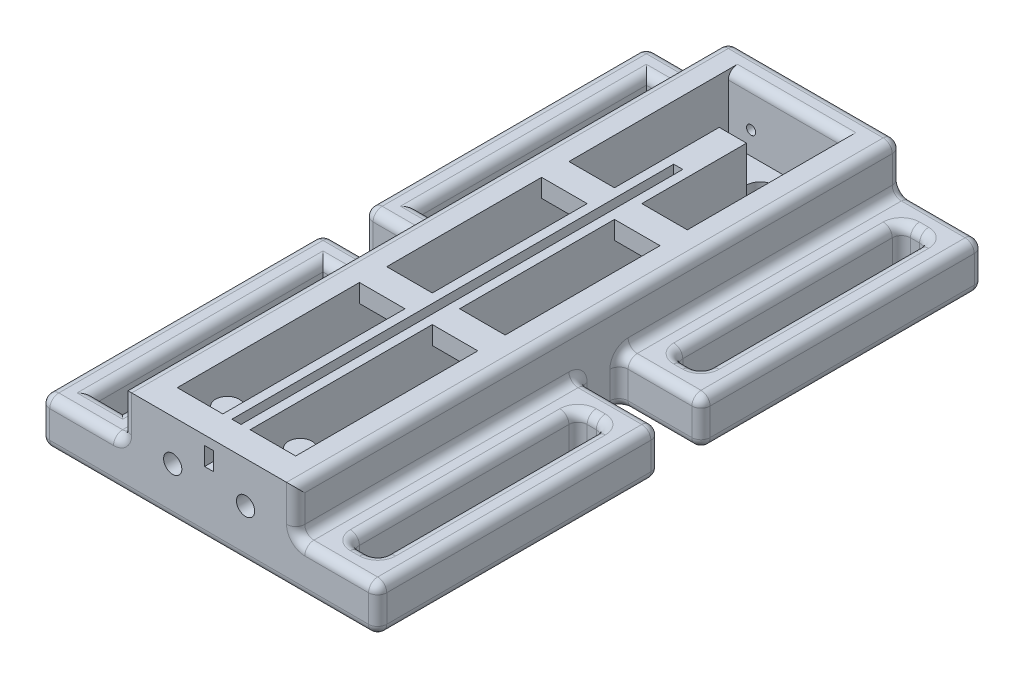
from build123d import *

# Parameters (mm, degrees)
SKETCH1_W           = 19
SKETCH1_H           = 66.5
BOSS_EXTRUDE2_DEPTH = 10
SKETCH2_W           = 5
SKETCH2_H           = 60.5
CUT_EXTRUDE1_DEPTH  = 7
SKETCH3_W           = 9
SKETCH3_H           = 31
SKETCH3_W_2         = 3
SKETCH3_H_2         = 25
BOSS_EXTRUDE3_DEPTH = 5
SKETCH4_R           = 1.3
BOSS_EXTRUDE4_DEPTH = 5
SKETCH5_W           = 13
SKETCH5_H           = 3
BOSS_EXTRUDE5_DEPTH = 2
SKETCH6_R           = 1.51
CUT_EXTRUDE4_DEPTH  = 10
SKETCH7_W           = 3
SKETCH7_H           = 6
CUT_EXTRUDE5_DEPTH  = 7
SKETCH10_R          = 0.5
CUT_EXTRUDE6_DEPTH  = 3
SKETCH11_R          = 1
CUT_EXTRUDE7_DEPTH  = 3
CUT_EXTRUDE8_DEPTH  = 3
SKETCH13_W          = 1
SKETCH13_H          = 2
CUT_EXTRUDE9_DEPTH  = 68
FILLET1_R           = 1


with BuildPart() as part:
    # Sketch1 → Boss-Extrude2 (new body)
    with BuildSketch(Plane(origin=(0, 0, 0), x_dir=(1, 0, 0), z_dir=(0, 1, 0))):
        with Locations((9.5, 33.25)):
            Rectangle(SKETCH1_W, SKETCH1_H)
    extrude(amount=BOSS_EXTRUDE2_DEPTH)

    # Sketch2 → Cut-Extrude1 (cut)
    with BuildSketch(Plane(origin=(0, 10, 0), x_dir=(1, 0, 0), z_dir=(0, 1, 0))):
        with Locations((5.5, 33.25)):
            Rectangle(SKETCH2_W, SKETCH2_H)
        with Locations((13.5, 33.25)):
            Rectangle(SKETCH2_W, SKETCH2_H)
    extrude(amount=-CUT_EXTRUDE1_DEPTH, mode=Mode.SUBTRACT)

    # Sketch3 → Boss-Extrude3 (add)
    with BuildSketch(Plane(origin=(0, 0, 0), x_dir=(1, 0, 0), z_dir=(0, 1, 0))):
        with Locations((-4.5, 15.5)):
            Rectangle(SKETCH3_W, SKETCH3_H)
        with Locations((-4.5, 15.5)):
            Rectangle(SKETCH3_W_2, SKETCH3_H_2, mode=Mode.SUBTRACT)
        with Locations((23.5, 15.5)):
            Rectangle(SKETCH3_W, SKETCH3_H)
        with Locations((23.5, 15.5)):
            Rectangle(SKETCH3_W_2, SKETCH3_H_2, mode=Mode.SUBTRACT)
        with Locations((-4.5, 51)):
            Rectangle(SKETCH3_W, SKETCH3_H)
        with Locations((-4.5, 51)):
            Rectangle(SKETCH3_W_2, SKETCH3_H_2, mode=Mode.SUBTRACT)
        with Locations((23.5, 51)):
            Rectangle(SKETCH3_W, SKETCH3_H)
        with Locations((23.5, 51)):
            Rectangle(SKETCH3_W_2, SKETCH3_H_2, mode=Mode.SUBTRACT)
    extrude(amount=BOSS_EXTRUDE3_DEPTH)

    # Sketch4 → Boss-Extrude4 (add)
    with BuildSketch(Plane(origin=(0, 3, 0), x_dir=(1, 0, 0), z_dir=(0, 1, 0))):
        with Locations((5.5, 6)):
            Circle(SKETCH4_R)
        with Locations((13.5, 6)):
            Circle(SKETCH4_R)
    extrude(amount=BOSS_EXTRUDE4_DEPTH)

    # Sketch5 → Boss-Extrude5 (add)
    with BuildSketch(Plane(origin=(0, 10, 0), x_dir=(1, 0, 0), z_dir=(0, 1, 0))):
        with Locations((9.5, 24.5)):
            Rectangle(SKETCH5_W, SKETCH5_H)
        with Locations((9.5, 44.5)):
            Rectangle(SKETCH5_W, SKETCH5_H)
    extrude(amount=-BOSS_EXTRUDE5_DEPTH)

    # Sketch6 → Cut-Extrude4 (cut)
    with BuildSketch(Plane(origin=(0, 10, 0), x_dir=(1, 0, 0), z_dir=(0, 1, 0))):
        with Locations((9.5, 60.5)):
            Circle(SKETCH6_R)
    extrude(amount=-CUT_EXTRUDE4_DEPTH, mode=Mode.SUBTRACT)

    # Sketch7 → Cut-Extrude5 (cut)
    with BuildSketch(Plane(origin=(0, 10, 0), x_dir=(1, 0, 0), z_dir=(0, 1, 0))):
        with Locations((9.5, 60.5)):
            Rectangle(SKETCH7_W, SKETCH7_H)
    extrude(amount=-CUT_EXTRUDE5_DEPTH, mode=Mode.SUBTRACT)

    # Sketch10 → Cut-Extrude6 (cut)
    with BuildSketch(Plane.XY.offset(-66.5)):
        with Locations((5.5, 5.5)):
            Circle(SKETCH10_R)
        with Locations((13.5, 5.5)):
            Circle(SKETCH10_R)
    extrude(amount=CUT_EXTRUDE6_DEPTH, mode=Mode.SUBTRACT)

    # Sketch11 → Cut-Extrude7 (cut)
    with BuildSketch(Plane(origin=(0, 0, -3), x_dir=(-1, 0, 0), z_dir=(0, 0, -1))):
        with Locations((-13.5, 5.5)):
            Circle(SKETCH11_R)
        with Locations((-5.5, 5.5)):
            Circle(SKETCH11_R)
    extrude(amount=-CUT_EXTRUDE7_DEPTH, mode=Mode.SUBTRACT)

    # Sketch12 → Cut-Extrude8 (cut)
    with BuildSketch(Plane(origin=(0, 10, 0), x_dir=(1, 0, 0), z_dir=(0, 1, 0))):
        Polygon((9, 11.5), (9, 3), (10, 3), (10, 11.5), (10, 14.5), (10, 23), (10, 26), (10, 33.437114061), (10, 36.408295957), (10, 43), (10, 46), (10, 51.5), (9, 51.5), (9, 46), (9, 43), (9, 36.408295957), (9, 33.437114061), (9, 26), (9, 23), (9, 14.5), align=None)
    extrude(amount=-CUT_EXTRUDE8_DEPTH, mode=Mode.SUBTRACT)

    # Sketch13 → Cut-Extrude9 (cut)
    with BuildSketch(Plane(origin=(0, 0, -57.5), x_dir=(-1, 0, 0), z_dir=(0, 0, -1))):
        with Locations((-9.5, 8)):
            Rectangle(SKETCH13_W, SKETCH13_H)
    extrude(amount=-CUT_EXTRUDE9_DEPTH, mode=Mode.SUBTRACT)

    # Fillet1
    fillet1_edges = [part.edges().sort_by_distance(p)[0] for p in [
        (19, 10, -33.25),
        (19, 5, -51),
        (23.5, 5, -35.5),
        (28, 5, -51),
        (23.5, 5, -66.5),
        (22, 0, -51),
        (23.5, 0, -38.5),
        (25, 0, -51),
        (23.5, 0, -63.5),
        (23.5, 0, -35.5),
        (19, 2.5, -35.5),
        (28, 0, -51),
        (28, 2.5, -35.5),
        (28, 2.5, -66.5),
        (22, 5, -51),
        (22, 2.5, -38.5),
        (23.5, 5, -38.5),
        (25, 2.5, -38.5),
        (25, 5, -51),
        (25, 2.5, -63.5),
        (23.5, 5, -63.5),
        (22, 2.5, -63.5),
        (9.5, 10, -63.5),
        (0, 10, -33.25),
        (0, 0, -33.25),
        (0, 5, -15.5),
        (-4.5, 5, -31),
        (-9, 5, -15.5),
        (-4.5, 5, 0),
        (-4.5, 0, -31),
        (9.5, 0, 0),
        (0, 2.5, -31),
        (-9, 0, -15.5),
        (-9, 2.5, -31),
        (-9, 2.5, 0),
        (-6, 5, -15.5),
        (-4.5, 5, -3),
        (-3, 5, -15.5),
        (-4.5, 5, -28),
        (9.5, 0, -66.5),
        (19, 0, -33.25),
        (19, 5, -15.5),
        (23.5, 5, 0),
        (28, 5, -15.5),
        (23.5, 5, -31),
        (23.5, 0, -28),
        (22, 0, -15.5),
        (23.5, 0, -3),
        (25, 0, -15.5),
        (19, 2.5, -31),
        (28, 0, -15.5),
        (28, 2.5, 0),
        (23.5, 0, -31),
        (28, 2.5, -31),
        (22, 5, -15.5),
        (22, 2.5, -3),
        (23.5, 5, -3),
        (25, 2.5, -3),
        (25, 5, -15.5),
        (25, 2.5, -28),
        (23.5, 5, -28),
        (22, 2.5, -28),
        (9.5, 10, -66.5),
        (0, 7.5, 0),
        (19, 7.5, 0),
        (19, 7.5, -66.5),
        (0, 7.5, -66.5),
        (0, 5, -51),
        (-4.5, 5, -66.5),
        (-9, 5, -51),
        (-4.5, 5, -35.5),
        (0, 2.5, -35.5),
        (-9, 0, -51),
        (-9, 2.5, -66.5),
        (-4.5, 0, -35.5),
        (-9, 2.5, -35.5),
        (-6, 5, -51),
        (-4.5, 5, -38.5),
        (-3, 5, -51),
        (-4.5, 5, -63.5),
    ]]
    fillet(fillet1_edges, radius=FILLET1_R)


solid = part.part
